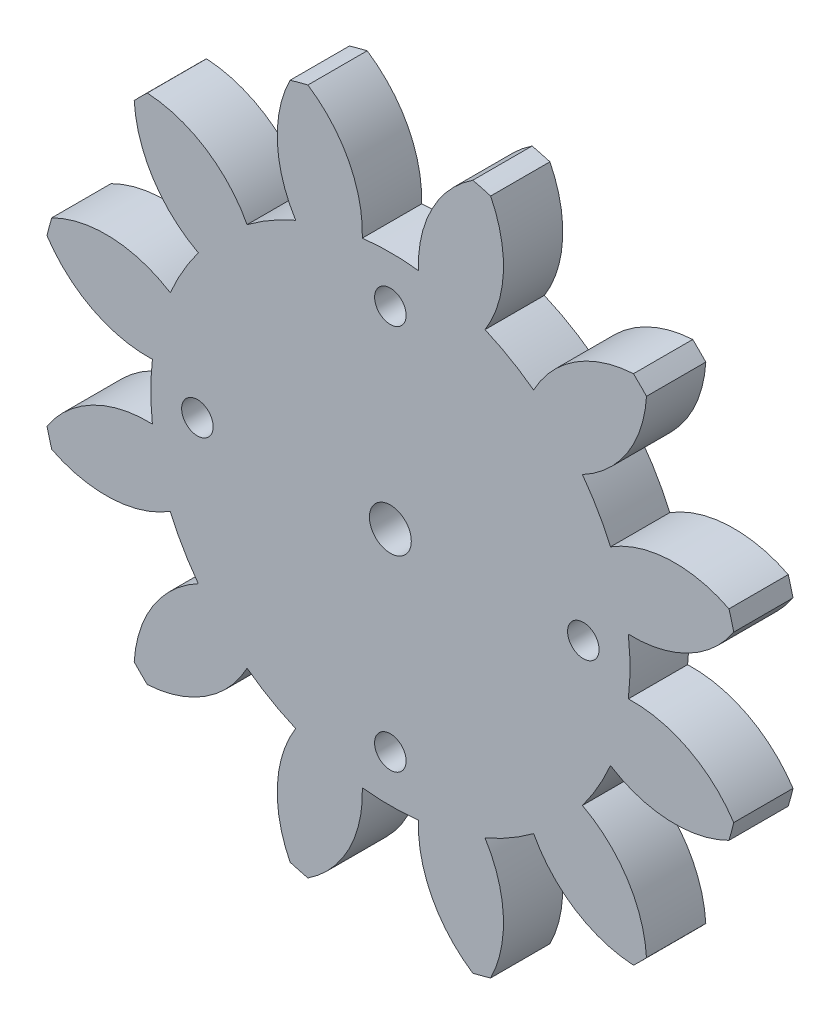
from build123d import *

# Parameters (mm, degrees)
SKETCH1_R           = 0.83
BOSS_EXTRUDE1_DEPTH = 2.35
SKETCH2_R           = 0.625
CUT_EXTRUDE1_DEPTH  = 10
CIRPATTERN1_COUNT   = 4


with BuildPart() as part:
    # Sketch1 → Boss-Extrude1 (new body)
    with BuildSketch(Plane.XY):
        with BuildLine():
            ThreePointArc((31.089190509, -0.00961289), (28.777823425, -0.762116774), (27.131493603, -2.550489779))
            ThreePointArc((27.131493603, -2.550489779), (26.201203233, -1.937982234), (25.205610954, -1.438580913))
            ThreePointArc((25.205610954, -1.438580913), (25.931222497, 0.881369039), (25.427226435, 3.259323592))
            ThreePointArc((25.427226435, 3.259323592), (25.075169864, 3.358604023), (24.720639715, 3.448652933))
            ThreePointArc((24.720639715, 3.448652933), (23.095189045, 1.641281911), (22.563612099, -0.730659454))
            ThreePointArc((22.563612099, -0.730659454), (21.451703233, -0.665357545), (20.339794367, -0.730659454))
            ThreePointArc((20.339794367, -0.730659454), (19.80821742, 1.641281911), (18.182766751, 3.448652933))
            ThreePointArc((18.182766751, 3.448652933), (17.828236601, 3.358604023), (17.47618003, 3.259323592))
            ThreePointArc((17.47618003, 3.259323592), (16.972183969, 0.881369039), (17.697795512, -1.438580913))
            ThreePointArc((17.697795512, -1.438580913), (16.702203233, -1.937982234), (15.771912863, -2.550489779))
            ThreePointArc((15.771912863, -2.550489779), (14.12558304, -0.762116774), (11.814215957, -0.00961289))
            ThreePointArc((11.814215957, -0.00961289), (11.552208296, -0.264862608), (11.296958578, -0.526870269))
            ThreePointArc((11.296958578, -0.526870269), (12.049462462, -2.838237352), (13.837835467, -4.484567174))
            ThreePointArc((13.837835467, -4.484567174), (13.225327922, -5.414857545), (12.725926601, -6.410449824))
            ThreePointArc((12.725926601, -6.410449824), (10.40597665, -5.684838281), (8.028022096, -6.188834342))
            ThreePointArc((8.028022096, -6.188834342), (7.928741665, -6.540890913), (7.838692755, -6.895421063))
            ThreePointArc((7.838692755, -6.895421063), (9.646063777, -8.520871732), (12.018005142, -9.052448679))
            ThreePointArc((12.018005142, -9.052448679), (11.952703233, -10.164357545), (12.018005142, -11.276266411))
            ThreePointArc((12.018005142, -11.276266411), (9.646063777, -11.807843357), (7.838692755, -13.433294027))
            ThreePointArc((7.838692755, -13.433294027), (7.928741665, -13.787824176), (8.028022096, -14.139880747))
            ThreePointArc((8.028022096, -14.139880747), (10.40597665, -14.643876808), (12.725926601, -13.918265265))
            ThreePointArc((12.725926601, -13.918265265), (13.225327922, -14.913857545), (13.837835467, -15.844147915))
            ThreePointArc((13.837835467, -15.844147915), (12.049462462, -17.490477737), (11.296958578, -19.80184482))
            ThreePointArc((11.296958578, -19.80184482), (11.552208296, -20.063852481), (11.814215957, -20.3191022))
            ThreePointArc((11.814215957, -20.3191022), (14.12558304, -19.566598315), (15.771912863, -17.77822531))
            ThreePointArc((15.771912863, -17.77822531), (16.702203233, -18.390732855), (17.697795512, -18.890134176))
            ThreePointArc((17.697795512, -18.890134176), (16.972183969, -21.210084128), (17.47618003, -23.588038682))
            ThreePointArc((17.47618003, -23.588038682), (17.828236601, -23.687319113), (18.182766751, -23.777368023))
            ThreePointArc((18.182766751, -23.777368023), (19.80821742, -21.969997001), (20.339794367, -19.598055636))
            ThreePointArc((20.339794367, -19.598055636), (21.451703233, -19.663357545), (22.563612099, -19.598055636))
            ThreePointArc((22.563612099, -19.598055636), (23.095189045, -21.969997001), (24.720639715, -23.777368023))
            ThreePointArc((24.720639715, -23.777368023), (25.075169864, -23.687319113), (25.427226435, -23.588038682))
            ThreePointArc((25.427226435, -23.588038682), (25.931222497, -21.210084128), (25.205610954, -18.890134176))
            ThreePointArc((25.205610954, -18.890134176), (26.201203233, -18.390732855), (27.131493603, -17.77822531))
            ThreePointArc((27.131493603, -17.77822531), (28.777823425, -19.566598315), (31.089190509, -20.3191022))
            ThreePointArc((31.089190509, -20.3191022), (31.351198169, -20.063852481), (31.606447888, -19.80184482))
            ThreePointArc((31.606447888, -19.80184482), (30.853944004, -17.490477737), (29.065570998, -15.844147915))
            ThreePointArc((29.065570998, -15.844147915), (29.678078543, -14.913857545), (30.177479864, -13.918265265))
            ThreePointArc((30.177479864, -13.918265265), (32.497429816, -14.643876808), (34.87538437, -14.139880747))
            ThreePointArc((34.87538437, -14.139880747), (34.974664801, -13.787824176), (35.064713711, -13.433294027))
            ThreePointArc((35.064713711, -13.433294027), (33.257342689, -11.807843357), (30.885401324, -11.276266411))
            ThreePointArc((30.885401324, -11.276266411), (30.950703233, -10.164357545), (30.885401324, -9.052448679))
            ThreePointArc((30.885401324, -9.052448679), (33.257342689, -8.520871732), (35.064713711, -6.895421063))
            ThreePointArc((35.064713711, -6.895421063), (34.974664801, -6.540890913), (34.87538437, -6.188834342))
            ThreePointArc((34.87538437, -6.188834342), (32.497429816, -5.684838281), (30.177479864, -6.410449824))
            ThreePointArc((30.177479864, -6.410449824), (29.678078543, -5.414857545), (29.065570998, -4.484567174))
            ThreePointArc((29.065570998, -4.484567174), (30.853944004, -2.838237352), (31.606447888, -0.526870269))
            ThreePointArc((31.606447888, -0.526870269), (31.351198169, -0.264862608), (31.089190509, -0.00961289))
        make_face()
        with Locations((21.451703233, -10.164357545)):
            Circle(SKETCH1_R, mode=Mode.SUBTRACT)
    extrude(amount=BOSS_EXTRUDE1_DEPTH)

    # Sketch2 → Cut-Extrude1 (cut)
    with BuildSketch(Plane.XY.offset(2.35)):
        with Locations((21.451703233, -2.514357545)):
            Circle(SKETCH2_R)
    cut_extrude1 = extrude(amount=-CUT_EXTRUDE1_DEPTH, mode=Mode.SUBTRACT)

    # CirPattern1: Cut-Extrude1 ×4 about axis
    cirpattern1_axis = Axis((21.451703233, -10.164357545, 17.324311526), (0, 0, -1))
    for i in range(1, CIRPATTERN1_COUNT):
        add(cut_extrude1.rotate(cirpattern1_axis, i * 360 / CIRPATTERN1_COUNT), mode=Mode.SUBTRACT)


solid = part.part
